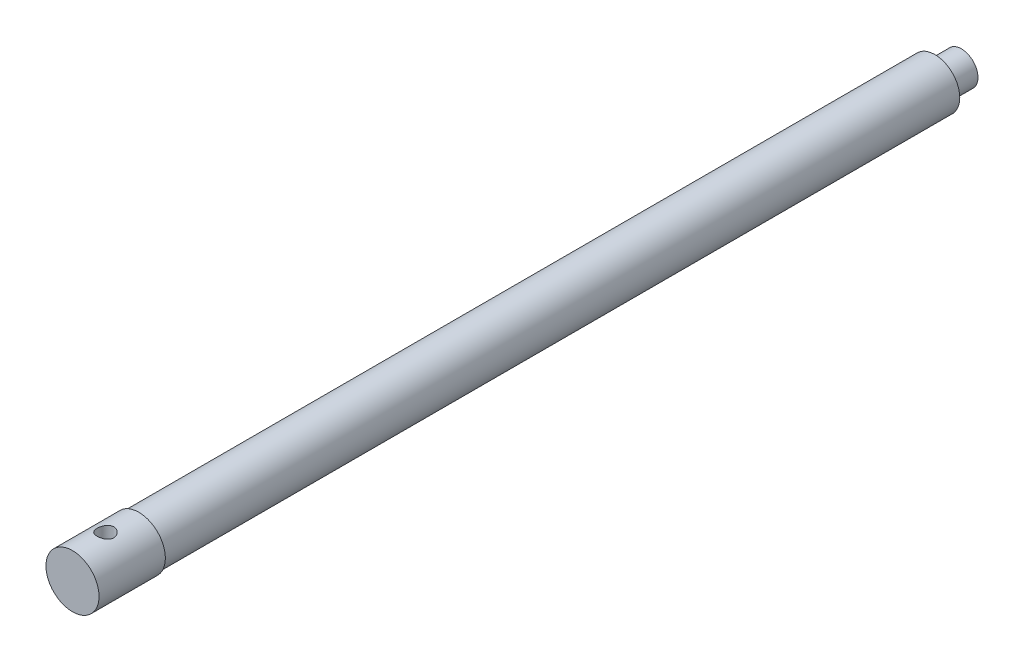
from build123d import *

# Parameters (mm, degrees)
SKETCH1_R               = 7.5
BOSS_EXTRUDE1_DEPTH     = 240
SKETCH5_R               = 8
BOSS_EXTRUDE2_DEPTH     = 20
SKETCH8_R               = 5
BOSS_EXTRUDE4_DEPTH     = 8
CUT_EXTRUDE3_DEPTH      = 8
CUT_EXTRUDE3_DEPTH_BACK = 8
SKETCH9_R               = 2.5


with BuildPart() as part:
    # Sketch1 → Boss-Extrude1 (new body)
    with BuildSketch(Plane.XY):
        Circle(SKETCH1_R)
    extrude(amount=BOSS_EXTRUDE1_DEPTH)

    # Sketch5 → Boss-Extrude2 (add)
    with BuildSketch(Plane.XY.offset(240)):
        Circle(SKETCH5_R)
    extrude(amount=BOSS_EXTRUDE2_DEPTH)

    # Sketch8 → Boss-Extrude4 (add)
    with BuildSketch(Plane(origin=(0, 0, 0), x_dir=(-1, 0, 0), z_dir=(0, 0, -1))):
        Circle(SKETCH8_R)
    extrude(amount=BOSS_EXTRUDE4_DEPTH)

    # Sketch9 → Cut-Extrude3 (cut, two sides: drawn at the far end of the back side and taken through both)
    with BuildSketch(Plane(origin=(0, 0, 0), x_dir=(1, 0, 0), z_dir=(0, 1, 0)).offset(-CUT_EXTRUDE3_DEPTH_BACK)):
        with Locations((0, -250.064612311)):
            Circle(SKETCH9_R)
    extrude(amount=CUT_EXTRUDE3_DEPTH + CUT_EXTRUDE3_DEPTH_BACK, mode=Mode.SUBTRACT)


solid = part.part
